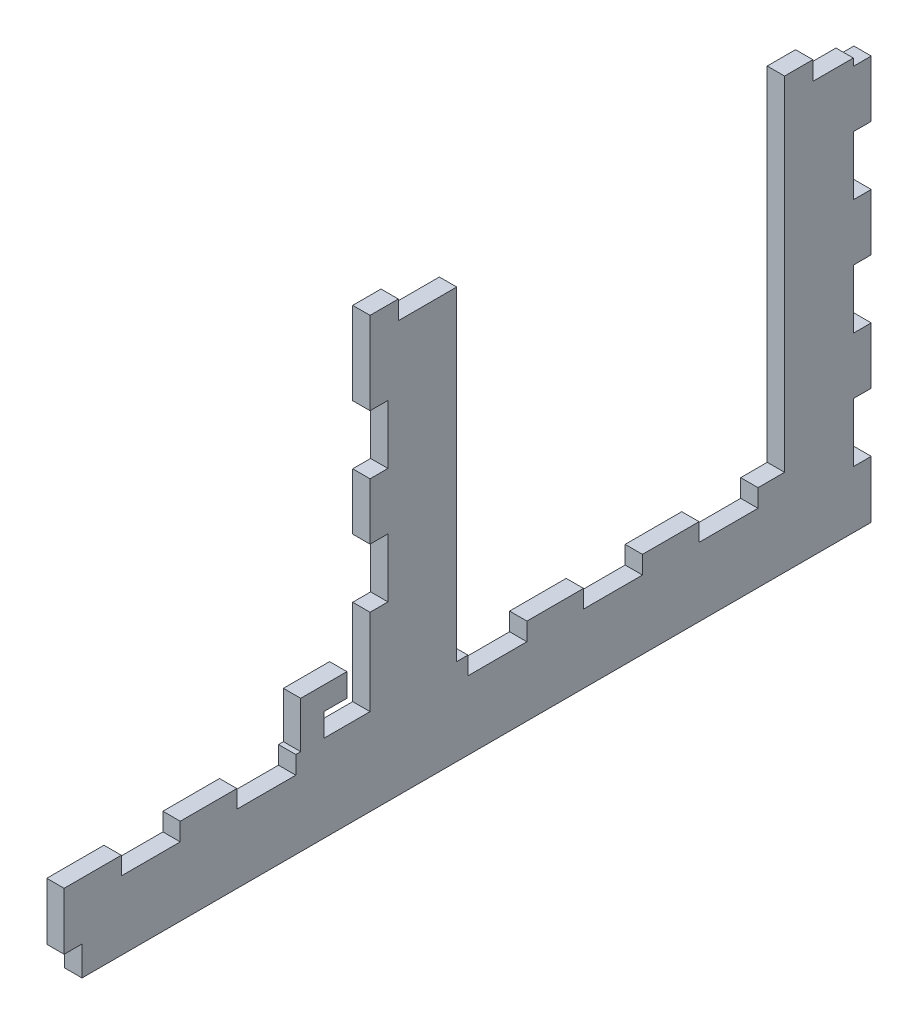
from build123d import *

# Parameters (mm, degrees)
BOSS_EXTRUDE1_DEPTH = 3
SKETCH6_W           = 3.2
SKETCH6_H           = 10.2
SKETCH6_H_2         = 5.2
SKETCH6_W_2         = 10.2
SKETCH6_H_3         = 3.2
CUT_EXTRUDE1_DEPTH  = 4
BOSS_EXTRUDE2_DEPTH = 3


with BuildPart() as part:
    # Sketch2 → Boss-Extrude1 (new body)
    with BuildSketch(Plane(origin=(34.872217102, 0, 0), x_dir=(0, 0, -1), z_dir=(1, 0, 0))):
        Polygon((103.744434203, 3), (103.744434203, -72), (-35.95, -72), (-35.95, -57), (17, -57), (17, 3), (32, 3), (32, -57), (88.744434203, -57), (88.744434203, 3), align=None)
    extrude(amount=-BOSS_EXTRUDE1_DEPTH)

    # Sketch6 → Cut-Extrude1 (cut, through all)
    with BuildSketch(Plane(origin=(34.872217102, 0, 0), x_dir=(0, 0, -1), z_dir=(1, 0, 0))):
        with Locations((102.244434203, -37)):
            Rectangle(SKETCH6_W, SKETCH6_H)
        with Locations((102.244434203, -57)):
            Rectangle(SKETCH6_W, SKETCH6_H)
        with Locations((102.244434203, -17)):
            Rectangle(SKETCH6_W, SKETCH6_H)
        with Locations((-34.45, -69.5)):
            Rectangle(SKETCH6_W, SKETCH6_H_2)
        with Locations((-20.95, -58.5)):
            Rectangle(SKETCH6_W_2, SKETCH6_H_3)
        with Locations((39.05, -58.5)):
            Rectangle(SKETCH6_W_2, SKETCH6_H_3)
        with Locations((-0.95, -58.5)):
            Rectangle(SKETCH6_W_2, SKETCH6_H_3)
        with Locations((18.5, -17)):
            Rectangle(SKETCH6_W, SKETCH6_H)
        with Locations((79.05, -58.5)):
            Rectangle(SKETCH6_W_2, SKETCH6_H_3)
        with Locations((59.05, -58.5)):
            Rectangle(SKETCH6_W_2, SKETCH6_H_3)
        Polygon((16.9, 2.4), (21.9, 2.4), (21.9, -0.85), (32.1, -0.85), (32.1, 3.1), (16.9, 3.1), align=None)
        Polygon((93.644434203, -0.85), (100.644434203, -0.85), (100.644434203, -2.1), (103.844434203, -2.1), (103.844434203, 3.1), (88.644434203, 3.1), (88.644434203, 2.4), (93.644434203, 2.4), align=None)
        with Locations((18.5, -37)):
            Rectangle(SKETCH6_W, SKETCH6_H)
    extrude(amount=-CUT_EXTRUDE1_DEPTH, mode=Mode.SUBTRACT)

    # Sketch8 → Boss-Extrude2 (add)
    with BuildSketch(Plane(origin=(34.872217102, 0, 0), x_dir=(0, 0, -1), z_dir=(1, 0, 0))):
        Polygon((13, -53), (13, -49), (5, -49), (5, -57), (9, -57), (9, -53), align=None)
    extrude(amount=-BOSS_EXTRUDE2_DEPTH)


solid = part.part
